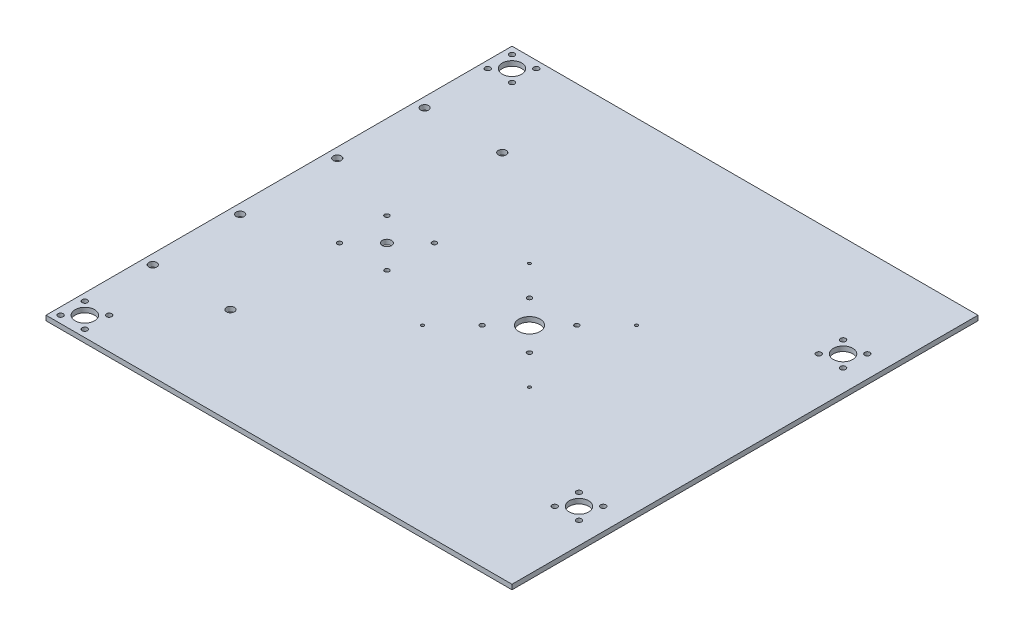
from build123d import *

# Parameters (mm, degrees)
SKETCH1_W               = 304.8
SKETCH1_H               = 304.8
BOSS_EXTRUDE1_DEPTH     = 3.175
SKETCH3_R               = 2.600000007
CUT_EXTRUDE1_DEPTH      = 4.175
SKETCH5_R               = 1.5
SKETCH5_R_2             = 2.999999969
CUT_EXTRUDE2_DEPTH      = 4.175
SKETCH7_R               = 0.999998
CUT_EXTRUDE3_DEPTH      = 4.175
SKETCH9_R               = 1.726999975
SKETCH9_R_2             = 6.35
CUT_EXTRUDE5_DEPTH      = 1
CUT_EXTRUDE5_DEPTH_BACK = 4.175
SKETCH11_R              = 1.5
SKETCH11_R_2            = 6.985
CUT_EXTRUDE6_DEPTH      = 1
CUT_EXTRUDE6_DEPTH_BACK = 4.175


with BuildPart() as part:
    # Sketch1 → Boss-Extrude1 (new body)
    with BuildSketch(Plane(origin=(0, 0, 0), x_dir=(1, 0, 0), z_dir=(0, 1, 0))):
        Rectangle(SKETCH1_W, SKETCH1_H)
    extrude(amount=BOSS_EXTRUDE1_DEPTH)

    # Sketch3 → Cut-Extrude1 (cut, through all)
    with BuildSketch(Plane(origin=(0, 3.175, 0), x_dir=(1, 0, 0), z_dir=(0, 1, 0))):
        with Locations((-146.05, -31.75)):
            Circle(SKETCH3_R)
        with Locations((-95.25, -88.9)):
            Circle(SKETCH3_R)
        with Locations((-146.05, -88.9)):
            Circle(SKETCH3_R)
    cut_extrude1 = extrude(amount=-CUT_EXTRUDE1_DEPTH, mode=Mode.SUBTRACT)

    # Mirror1: Cut-Extrude1 across plane
    add(cut_extrude1.mirror(Plane.XY), mode=Mode.SUBTRACT)

    # Sketch5 → Cut-Extrude2 (cut, through all)
    with BuildSketch(Plane(origin=(0, 3.175, 0), x_dir=(1, 0, 0), z_dir=(0, 1, 0))):
        with Locations((-66.312, 15.5)):
            Circle(SKETCH5_R)
        with Locations((-66.312, -15.5)):
            Circle(SKETCH5_R)
        with Locations((-97.312, 15.5)):
            Circle(SKETCH5_R)
        with Locations((-97.312, -15.5)):
            Circle(SKETCH5_R)
        with Locations((-81.812, 0)):
            Circle(SKETCH5_R_2)
    extrude(amount=-CUT_EXTRUDE2_DEPTH, mode=Mode.SUBTRACT)

    # Sketch7 → Cut-Extrude3 (cut, through all)
    with BuildSketch(Plane(origin=(0, 3.175, 0), x_dir=(1, 0, 0), z_dir=(0, 1, 0))):
        with Locations((46.431787507, -35.001787507)):
            Circle(SKETCH7_R)
        with Locations((-23.571787507, -35.001787507)):
            Circle(SKETCH7_R)
        with Locations((-23.571787507, 35.001787507)):
            Circle(SKETCH7_R)
        with Locations((46.431787507, 35.001787507)):
            Circle(SKETCH7_R)
    extrude(amount=-CUT_EXTRUDE3_DEPTH, mode=Mode.SUBTRACT)

    # Sketch9 → Cut-Extrude5 (cut, two sides)
    with BuildSketch(Plane(origin=(0, 3.175, 0), x_dir=(1, 0, 0), z_dir=(0, 1, 0))) as cut_extrude5_sk:
        with Locations((-131.7625, -147.6375)):
            Circle(SKETCH9_R)
        with Locations((-131.7625, -131.7625)):
            Circle(SKETCH9_R)
        with Locations((-147.6375, -131.7625)):
            Circle(SKETCH9_R)
        with Locations((-147.6375, -147.6375)):
            Circle(SKETCH9_R)
        with Locations((-139.7, -139.7)):
            Circle(SKETCH9_R_2)
        with Locations((138.1125, -94.2975)):
            Circle(SKETCH9_R)
        with Locations((138.1125, -78.4225)):
            Circle(SKETCH9_R)
        with Locations((130.175, -86.36)):
            Circle(SKETCH9_R_2)
        with Locations((122.2375, -78.4225)):
            Circle(SKETCH9_R)
        with Locations((122.2375, -94.2975)):
            Circle(SKETCH9_R)
        with Locations((122.2375, 94.2975)):
            Circle(SKETCH9_R)
        with Locations((122.2375, 78.4225)):
            Circle(SKETCH9_R)
        with Locations((138.1125, 94.2975)):
            Circle(SKETCH9_R)
        with Locations((130.175, 86.36)):
            Circle(SKETCH9_R_2)
        with Locations((138.1125, 78.4225)):
            Circle(SKETCH9_R)
        with Locations((-131.7625, 131.7625)):
            Circle(SKETCH9_R)
        with Locations((-131.7625, 147.6375)):
            Circle(SKETCH9_R)
        with Locations((-147.6375, 147.6375)):
            Circle(SKETCH9_R)
        with Locations((-147.6375, 131.7625)):
            Circle(SKETCH9_R)
        with Locations((-139.7, 139.7)):
            Circle(SKETCH9_R_2)
    extrude(amount=CUT_EXTRUDE5_DEPTH, mode=Mode.SUBTRACT)
    extrude(cut_extrude5_sk.sketch, amount=-CUT_EXTRUDE5_DEPTH_BACK, mode=Mode.SUBTRACT)

    # Sketch11 → Cut-Extrude6 (cut, two sides)
    with BuildSketch(Plane(origin=(0, 3.175, 0), x_dir=(1, 0, 0), z_dir=(0, 1, 0))) as cut_extrude6_sk:
        with Locations((26.93, 15.5)):
            Circle(SKETCH11_R)
        with Locations((26.93, -15.5)):
            Circle(SKETCH11_R)
        with Locations((-4.07, -15.5)):
            Circle(SKETCH11_R)
        with Locations((-4.07, 15.5)):
            Circle(SKETCH11_R)
        with Locations((11.43, 0)):
            Circle(SKETCH11_R_2)
    extrude(amount=CUT_EXTRUDE6_DEPTH, mode=Mode.SUBTRACT)
    extrude(cut_extrude6_sk.sketch, amount=-CUT_EXTRUDE6_DEPTH_BACK, mode=Mode.SUBTRACT)


solid = part.part
